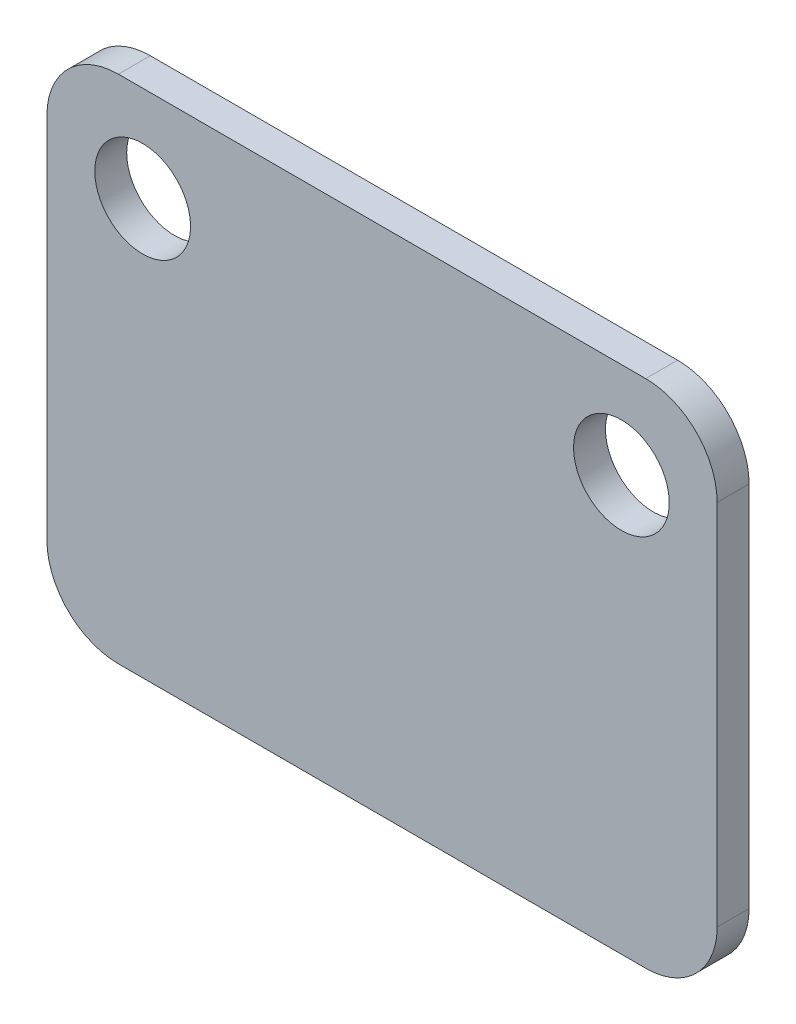
from build123d import *

# Parameters (mm, degrees)
RESSALTO_EXTRUS_O2_DEPTH = 1
ESBO_O7_R                = 1.5
CORTE_EXTRUS_O4_DEPTH    = 3


with BuildPart() as part:
    # Esboço6 → Ressalto-extrusão2 (new body)
    with BuildSketch(Plane.XY):
        with BuildLine():
            Line((71.351910343, 949.056430092), (54.831910343, 949.056430092))
            ThreePointArc((54.831910343, 949.056430092), (53.247991153, 948.400349282), (52.591910343, 946.816430092))
            Line((52.591910343, 946.816430092), (52.591910343, 935.296430092))
            ThreePointArc((52.591910343, 935.296430092), (53.247991153, 933.712510902), (54.831910343, 933.056430092))
            Line((54.831910343, 933.056430092), (71.351910343, 933.056430092))
            ThreePointArc((71.351910343, 933.056430092), (72.935829533, 933.712510902), (73.591910343, 935.296430092))
            Line((73.591910343, 935.296430092), (73.591910343, 946.816430092))
            ThreePointArc((73.591910343, 946.816430092), (72.935829533, 948.400349282), (71.351910343, 949.056430092))
        make_face()
    extrude(amount=RESSALTO_EXTRUS_O2_DEPTH)

    # Esboço7 → Corte-extrusão4 (cut)
    with BuildSketch(Plane(origin=(0, 0, 0), x_dir=(-1, 0, 0), z_dir=(0, 0, -1))):
        with Locations((-55.591910343, 946.056430092)):
            Circle(ESBO_O7_R)
        with Locations((-70.591910343, 946.056430092)):
            Circle(ESBO_O7_R)
    extrude(amount=-CORTE_EXTRUS_O4_DEPTH, mode=Mode.SUBTRACT)


solid = part.part
